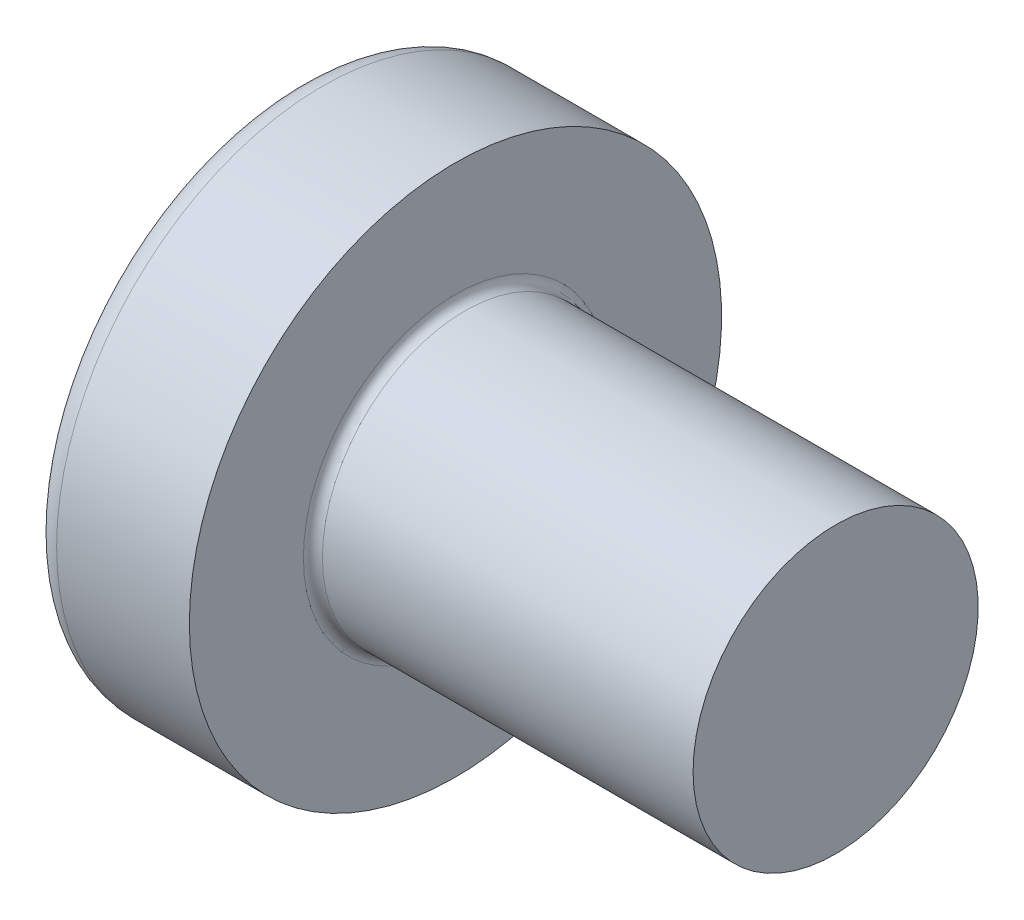
from build123d import *

# Parameters (mm, degrees)
FILLET1_R    = 0.1
SKETCH3_W    = 0.74
SKETCH3_H    = 2.8
SKETCH4_W    = 0.74
SKETCH4_H    = 1.054964664
RECPAT_COUNT = 2
RECPAT_ANGLE = 90


with BuildPart() as part:
    # BodySke → Base-Revolve (revolve)
    with BuildSketch(Plane.XY):
        with BuildLine():
            Line((2.4, 1.5), (2.4, 2.8))
            Line((2.4, 2.8), (1.003501533, 2.8))
            ThreePointArc((1.003501533, 2.8), (0.873295971, 2.76653015), (0.775371599, 2.674418605))
            ThreePointArc((0.775371599, 2.674418605), (0.197753546, 1.392274756), (0, 0))
            Line((0, 0), (6.4, 0))
            Line((6.4, 0), (6.4, 1.5))
            Line((6.4, 1.5), (2.4, 1.5))
        make_face()
    revolve(axis=Axis((-25.4, 0, 0), (1, 0, 0)))

    # Fillet1
    fillet1_edges = [part.edges().sort_by_distance(p)[0] for p in [
        (2.4, -1.5, 0),
    ]]
    fillet(fillet1_edges, radius=FILLET1_R)

    # Sketch3 → Recess section 0
    with BuildSketch(Plane(origin=(0, 0, 0), x_dir=(0, 0, -1), z_dir=(1, 0, 0))):
        Rectangle(SKETCH3_W, SKETCH3_H)
    # Sketch4 → Recess section 1
    with BuildSketch(Plane(origin=(1.75, 0, 0), x_dir=(0, 0, -1), z_dir=(1, 0, 0))):
        Rectangle(SKETCH4_W, SKETCH4_H)
    recess = loft(mode=Mode.SUBTRACT)

    # RecPat: Recess ×2 about axis
    recpat_axis = Axis((0, 0, 0), (1, 0, 0))
    for i in range(1, RECPAT_COUNT):
        add(recess.rotate(recpat_axis, i * RECPAT_ANGLE / (RECPAT_COUNT - 1)), mode=Mode.SUBTRACT)

    # RecCorSke → RecessCore (revolve, cut)
    with BuildSketch(Plane.XY):
        Polygon((0, 0), (0, 0.678371921), (1.75, 0.556), (1.930655351, 0), align=None)
    revolve(axis=Axis((-3.175, 0, 0), (1, 0, 0)), mode=Mode.SUBTRACT)


solid = part.part
